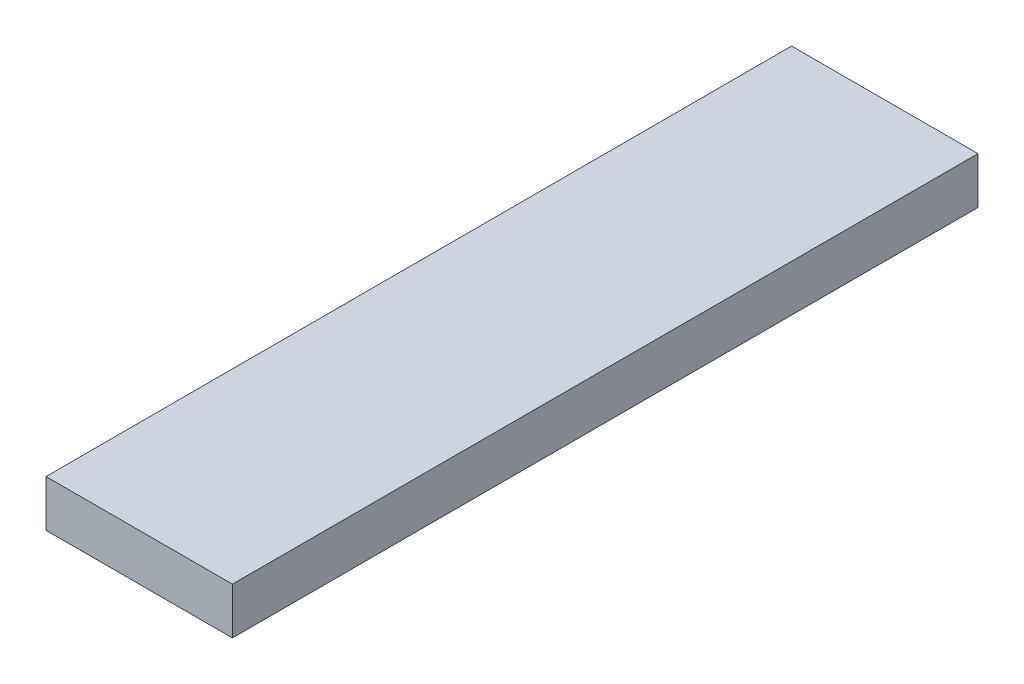
from build123d import *

# Parameters (mm, degrees)
BOSS_EXTRU_1_DEPTH = 32
CHANFREIN1_SIZE    = 1.5


with BuildPart() as part:
    # Esquisse1 → Boss.-Extru.1 (new body)
    with BuildSketch(Plane.XY):
        Polygon((-4, 0), (4, 0), (4, -2), (2.5, -3.5), (-2.5, -3.5), (-4, -2), align=None)
    extrude(amount=BOSS_EXTRU_1_DEPTH)

    # Chanfrein1
    chanfrein1_edges = [part.edges().sort_by_distance(p)[0] for p in [
        (0, -3.5, 0),
        (0, -3.5, 32),
    ]]
    chamfer(chanfrein1_edges, length=CHANFREIN1_SIZE)


solid = part.part
